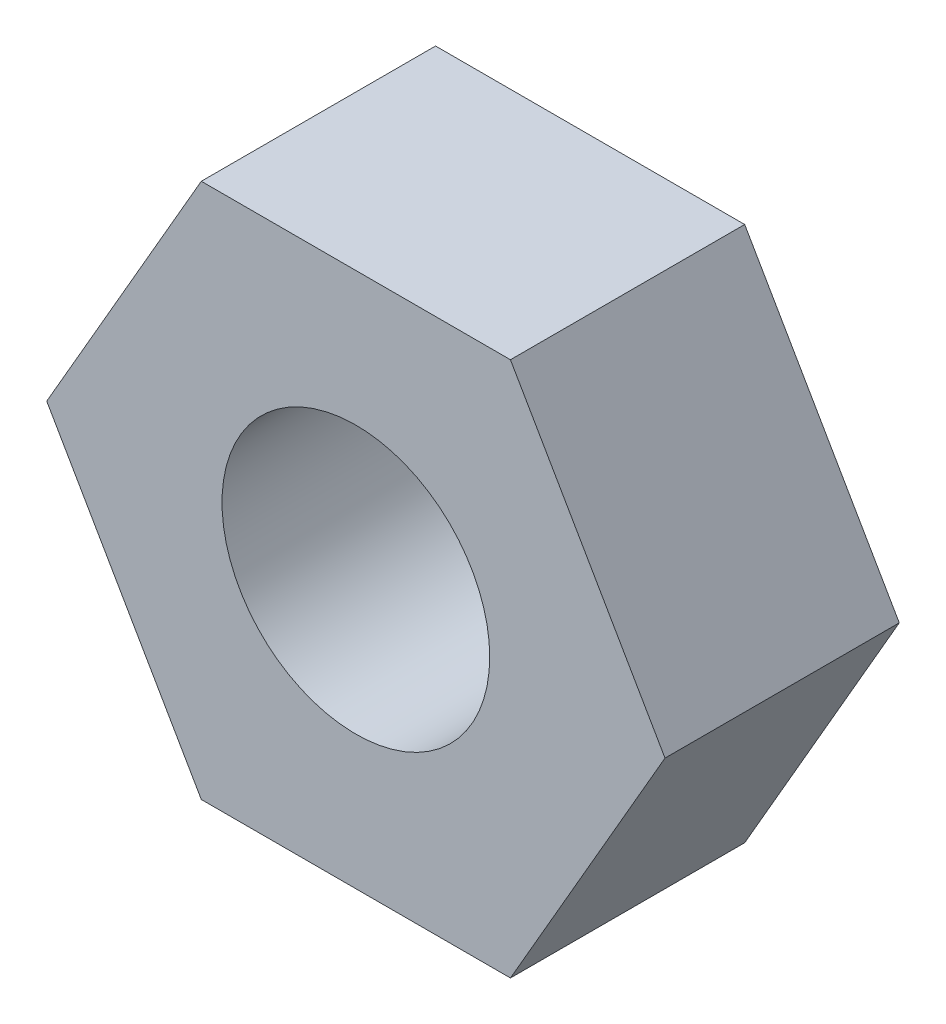
from build123d import *

# Parameters (mm, degrees)
SKETCH1_R           = 8
BOSS_EXTRUDE1_DEPTH = 14


with BuildPart() as part:
    # Sketch1 → Boss-Extrude1 (new body)
    with BuildSketch(Plane.XY):
        Polygon((18.475208614, 0), (9.237604307, 16), (-9.237604307, 16), (-18.475208614, 0), (-9.237604307, -16), (9.237604307, -16), align=None)
        Circle(SKETCH1_R, mode=Mode.SUBTRACT)
    extrude(amount=BOSS_EXTRUDE1_DEPTH)


solid = part.part
